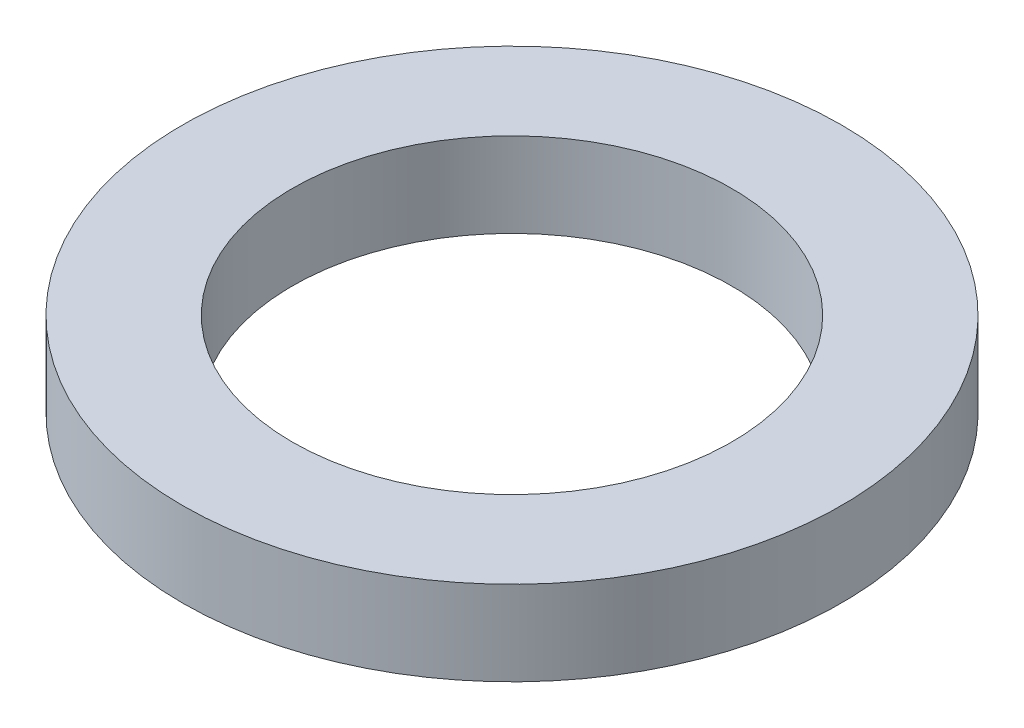
from build123d import *

# Parameters (mm, degrees)
SZKIC1_R                    = 9.75
SZKIC1_R_2                  = 6.5
DODANIE_WYCI_GNI_CIE1_DEPTH = 2.5


with BuildPart() as part:
    # Szkic1 → Dodanie-wyciągnięcie1 (new body)
    with BuildSketch(Plane(origin=(0, 0, 0), x_dir=(1, 0, 0), z_dir=(0, 1, 0))):
        Circle(SZKIC1_R)
        Circle(SZKIC1_R_2, mode=Mode.SUBTRACT)
    extrude(amount=DODANIE_WYCI_GNI_CIE1_DEPTH)


solid = part.part
